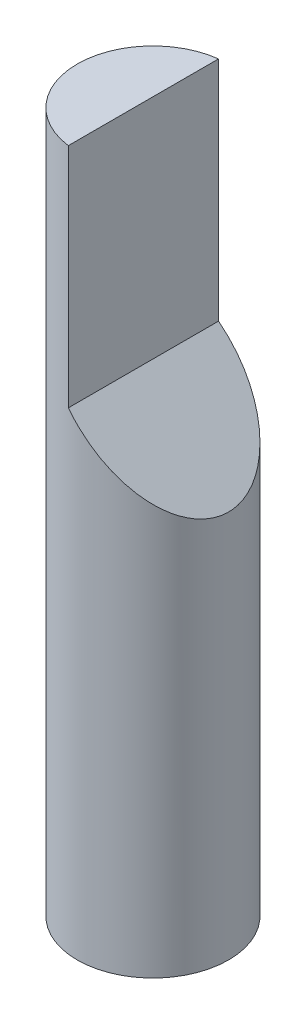
from build123d import *

# Parameters (mm, degrees)
SKETCH1_R               = 0.4
BOSS_EXTRUDE1_DEPTH     = 3.7
CUT_EXTRUDE1_DEPTH      = 1.4
CUT_EXTRUDE1_DEPTH_BACK = 1.4


with BuildPart() as part:
    # Sketch1 → Boss-Extrude1 (new body)
    with BuildSketch(Plane(origin=(0, 0, 0), x_dir=(1, 0, 0), z_dir=(0, 1, 0))):
        Circle(SKETCH1_R)
    extrude(amount=BOSS_EXTRUDE1_DEPTH)

    # Sketch3 → Cut-Extrude1 (cut, two sides)
    with BuildSketch(Plane.XY) as cut_extrude1_sk:
        Polygon((-0.05, 3.7), (-0.05, 2.5), (0.4, 2.05), (0.4, 3.7), align=None)
    extrude(amount=CUT_EXTRUDE1_DEPTH, mode=Mode.SUBTRACT)
    extrude(cut_extrude1_sk.sketch, amount=-CUT_EXTRUDE1_DEPTH_BACK, mode=Mode.SUBTRACT)


solid = part.part
